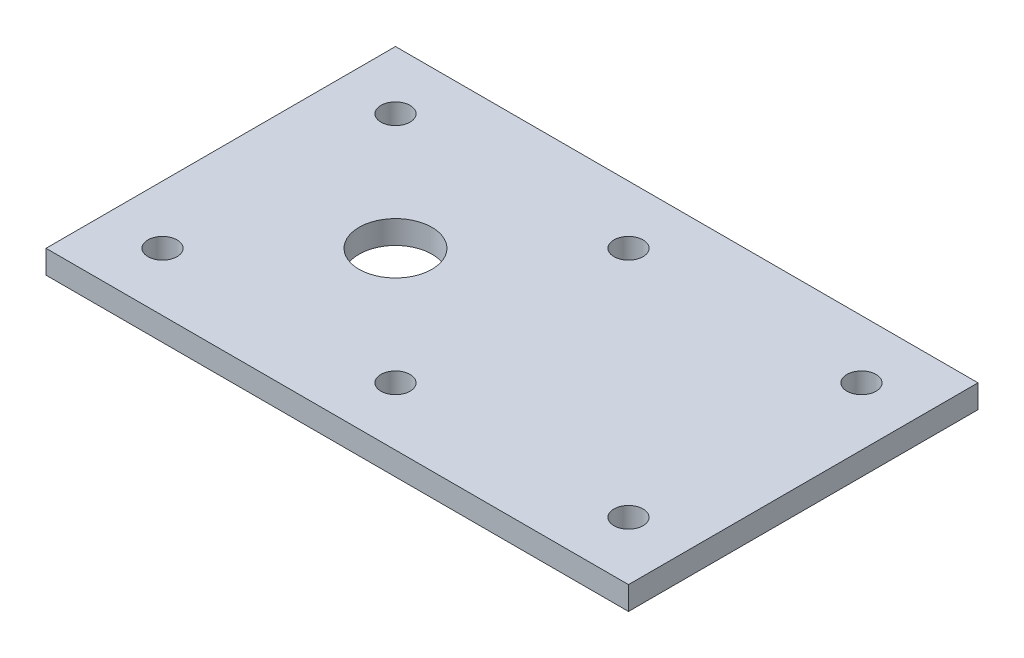
from build123d import *

# Parameters (mm, degrees)
SKETCH2_W            = 200
SKETCH2_H            = 120
BOSS_EXTRUDE3_DEPTH  = 8
SKETCH3_R            = 5
CUT_EXTRUDE1_DEPTH   = 9
LPATTERN2_COUNT      = 2
LPATTERN2_PITCH      = 80
LPATTERN2_COUNT_DIR2 = 3
LPATTERN2_PITCH_DIR2 = 80
SKETCH4_R            = 12.5
CUT_EXTRUDE2_DEPTH   = 10


with BuildPart() as part:
    # Sketch2 → Boss-Extrude3 (new body)
    with BuildSketch(Plane(origin=(0, 0, 0), x_dir=(1, 0, 0), z_dir=(0, 1, 0))):
        with Locations((40, 0)):
            Rectangle(SKETCH2_W, SKETCH2_H)
    extrude(amount=BOSS_EXTRUDE3_DEPTH)

    # Sketch3 → Cut-Extrude1 (cut, through all)
    with BuildSketch(Plane(origin=(0, 8, 0), x_dir=(1, 0, 0), z_dir=(0, 1, 0))):
        with Locations((-40, 40)):
            Circle(SKETCH3_R)
    cut_extrude1 = extrude(amount=-CUT_EXTRUDE1_DEPTH, mode=Mode.SUBTRACT)

    # LPattern2: Cut-Extrude1 2 × 3
    with Locations(*[(j * LPATTERN2_PITCH_DIR2, 0, i * LPATTERN2_PITCH) for i in range(LPATTERN2_COUNT) for j in range(LPATTERN2_COUNT_DIR2) if (i, j) != (0, 0)]):
        add(cut_extrude1, mode=Mode.SUBTRACT)

    # Sketch4 → Cut-Extrude2 (cut)
    with BuildSketch(Plane(origin=(0, 8, 0), x_dir=(1, 0, 0), z_dir=(0, 1, 0))):
        Circle(SKETCH4_R)
    extrude(amount=-CUT_EXTRUDE2_DEPTH, mode=Mode.SUBTRACT)


solid = part.part
